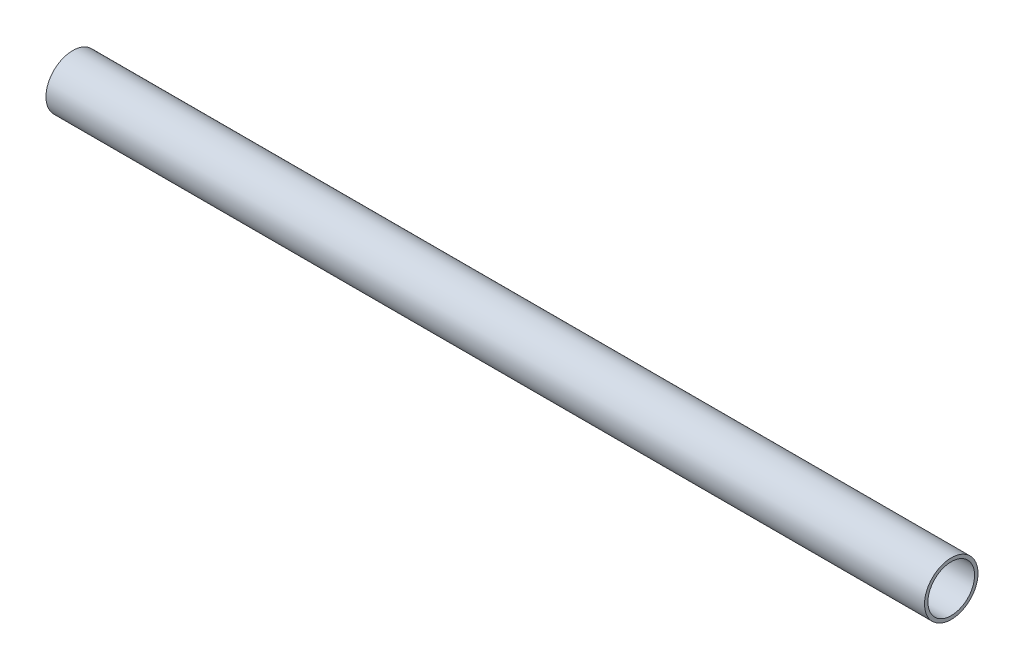
from build123d import *

# Parameters (mm, degrees)
SKETCH1_R      = 6.35
SKETCH1_R_2    = 5.5372
EXTRUDE1_DEPTH = 208.5721


with BuildPart() as part:
    # Sketch1 → Extrude1 (new body)
    with BuildSketch(Plane(origin=(0, 0, 0), x_dir=(0, 0, -1), z_dir=(1, 0, 0))):
        Circle(SKETCH1_R)
        Circle(SKETCH1_R_2, mode=Mode.SUBTRACT)
    extrude(amount=EXTRUDE1_DEPTH)


solid = part.part
